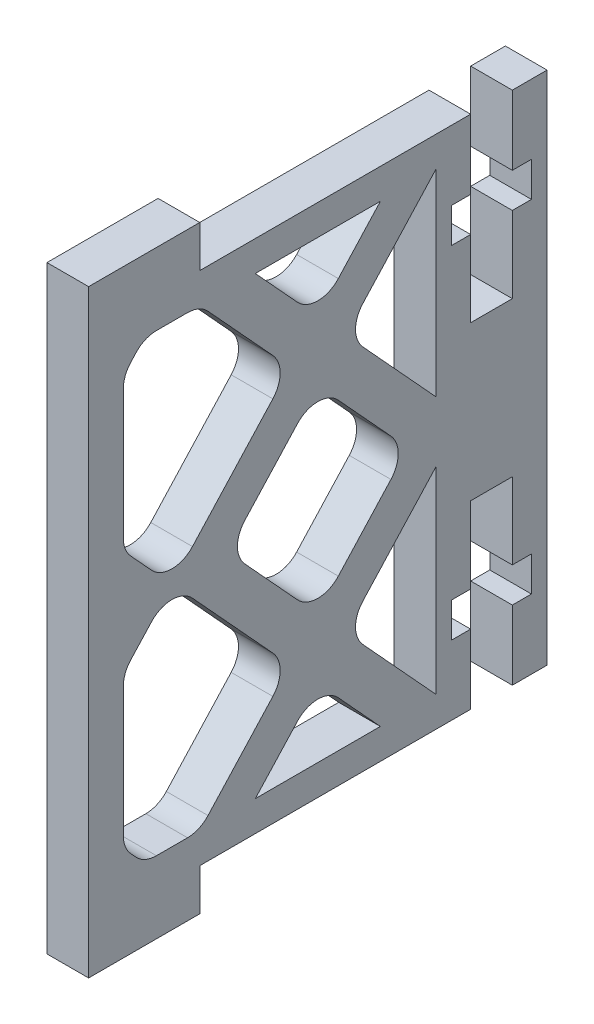
from build123d import *

# Parameters (mm, degrees)
RESSALTO_EXTRUS_O1_DEPTH = 3


with BuildPart() as part:
    # Esboço1 → Ressalto-extrusão1 (new body)
    with BuildSketch(Plane(origin=(0, 0, 0), x_dir=(0, 0, -1), z_dir=(1, 0, 0))):
        Polygon((9.606615439, 38.402396467), (-6.893384561, 38.402396467), (-6.893384561, 41.402396467), (-14.893384561, 41.402396467), (-14.893384561, 38.402396467), (-14.893384561, 1.302396467), (-14.893384561, -1.697603533), (-6.893384561, -1.697603533), (-6.893384561, 1.302396467), (9.606615439, 1.302396467), (10.106615439, 1.302396467), (12.106615439, 1.302396467), (12.606615439, 1.302396467), (12.606615439, 6.302396467), (11.231615439, 6.302396467), (11.231615439, 8.802396467), (12.606615439, 8.802396467), (12.606615439, 14.302396467), (15.606615439, 14.302396467), (15.606615439, 8.802396467), (16.981615439, 8.802396467), (16.981615439, 6.302396467), (15.606615439, 6.302396467), (15.606615439, 1.302396467), (18.106615439, 1.302396467), (18.106615439, 38.402396467), (15.606615439, 38.402396467), (15.606615439, 33.402396467), (16.981615439, 33.402396467), (16.981615439, 30.902396467), (15.606615439, 30.902396467), (15.606615439, 25.402396467), (12.606615439, 25.402396467), (12.606615439, 30.902396467), (11.231615439, 30.902396467), (11.231615439, 33.402396467), (12.606615439, 33.402396467), (12.606615439, 38.402396467), (12.106615439, 38.402396467), (10.106615439, 38.402396467), align=None)
        with BuildLine():
            Line((-7.41891132, 18.243485959), (-1.631744546, 11.928665745))
            ThreePointArc((-1.631744546, 11.928665745), (-1.106217787, 10.577396467), (-1.631744546, 9.226127189))
            Line((-1.631744546, 9.226127189), (-6.298860449, 4.13348013))
            ThreePointArc((-6.298860449, 4.13348013), (-6.967895473, 3.654102179), (-7.77333369, 3.484749408))
            Line((-7.77333369, 3.484749408), (-10.013435432, 3.484749408))
            ThreePointArc((-10.013435432, 3.484749408), (-10.818873649, 3.654102179), (-11.487908673, 4.13348013))
            Line((-11.487908673, 4.13348013), (-11.867857802, 4.54807168))
            ThreePointArc((-11.867857802, 4.54807168), (-12.257378456, 5.174408714), (-12.393384561, 5.899340958))
            Line((-12.393384561, 5.899340958), (-12.393384561, 15.255451976))
            ThreePointArc((-12.393384561, 15.255451976), (-12.257378456, 15.98038422), (-11.867857802, 16.606721254))
            Line((-11.867857802, 16.606721254), (-10.367857802, 18.243485959))
            ThreePointArc((-10.367857802, 18.243485959), (-8.893384561, 18.892216682), (-7.41891132, 18.243485959))
        make_face(mode=Mode.SUBTRACT)
        with BuildLine():
            Line((3.08108868, 6.786133018), (6.106615439, 3.484749408))
            Line((6.106615439, 3.484749408), (-2.893384561, 3.484749408))
            Line((-2.893384561, 3.484749408), (0.132142198, 6.786133018))
            ThreePointArc((0.132142198, 6.786133018), (1.606615439, 7.434863741), (3.08108868, 6.786133018))
        make_face(mode=Mode.SUBTRACT)
        with BuildLine():
            Line((10.106615439, 17.670043526), (10.106615439, 3.484749408))
            Line((10.106615439, 3.484749408), (9.512091327, 4.13348013))
            Line((9.512091327, 4.13348013), (4.844975424, 9.226127189))
            ThreePointArc((4.844975424, 9.226127189), (4.319448665, 10.577396467), (4.844975424, 11.928665745))
            Line((4.844975424, 11.928665745), (10.106615439, 17.670043526))
        make_face(mode=Mode.SUBTRACT)
        with BuildLine():
            ThreePointArc((3.08108868, 14.368659915), (1.606615439, 13.719929193), (0.132142198, 14.368659915))
            Line((0.132142198, 14.368659915), (-3.655024576, 18.501127189))
            ThreePointArc((-3.655024576, 18.501127189), (-4.180551335, 19.852396467), (-3.655024576, 21.203665745))
            Line((-3.655024576, 21.203665745), (0.132142198, 25.336133018))
            ThreePointArc((0.132142198, 25.336133018), (1.606615439, 25.984863741), (3.08108868, 25.336133018))
            Line((3.08108868, 25.336133018), (6.868255454, 21.203665745))
            ThreePointArc((6.868255454, 21.203665745), (7.393782213, 19.852396467), (6.868255454, 18.501127189))
            Line((6.868255454, 18.501127189), (3.08108868, 14.368659915))
        make_face(mode=Mode.SUBTRACT)
        with BuildLine():
            ThreePointArc((-11.867857802, 23.09807168), (-12.257378456, 23.724408714), (-12.393384561, 24.449340958))
            Line((-12.393384561, 24.449340958), (-12.393384561, 33.805451976))
            ThreePointArc((-12.393384561, 33.805451976), (-12.257378456, 34.53038422), (-11.867857802, 35.156721254))
            Line((-11.867857802, 35.156721254), (-11.487908673, 35.571312803))
            ThreePointArc((-11.487908673, 35.571312803), (-10.818873649, 36.050690755), (-10.013435432, 36.220043526))
            Line((-10.013435432, 36.220043526), (-7.77333369, 36.220043526))
            ThreePointArc((-7.77333369, 36.220043526), (-6.967895473, 36.050690755), (-6.298860449, 35.571312803))
            Line((-6.298860449, 35.571312803), (-1.631744546, 30.478665745))
            ThreePointArc((-1.631744546, 30.478665745), (-1.106217787, 29.127396467), (-1.631744546, 27.776127189))
            Line((-1.631744546, 27.776127189), (-7.41891132, 21.461306974))
            ThreePointArc((-7.41891132, 21.461306974), (-8.893384561, 20.812576252), (-10.367857802, 21.461306974))
            Line((-10.367857802, 21.461306974), (-11.867857802, 23.09807168))
        make_face(mode=Mode.SUBTRACT)
        with BuildLine():
            Line((9.512091327, 35.571312803), (10.106615439, 36.220043526))
            Line((10.106615439, 36.220043526), (10.106615439, 22.034749408))
            Line((10.106615439, 22.034749408), (4.844975424, 27.776127189))
            ThreePointArc((4.844975424, 27.776127189), (4.319448665, 29.127396467), (4.844975424, 30.478665745))
            Line((4.844975424, 30.478665745), (9.512091327, 35.571312803))
        make_face(mode=Mode.SUBTRACT)
        with BuildLine():
            Line((0.132142198, 32.918659915), (-2.893384561, 36.220043526))
            Line((-2.893384561, 36.220043526), (6.106615439, 36.220043526))
            Line((6.106615439, 36.220043526), (3.08108868, 32.918659915))
            ThreePointArc((3.08108868, 32.918659915), (1.606615439, 32.269929193), (0.132142198, 32.918659915))
        make_face(mode=Mode.SUBTRACT)
    extrude(amount=RESSALTO_EXTRUS_O1_DEPTH)


solid = part.part
